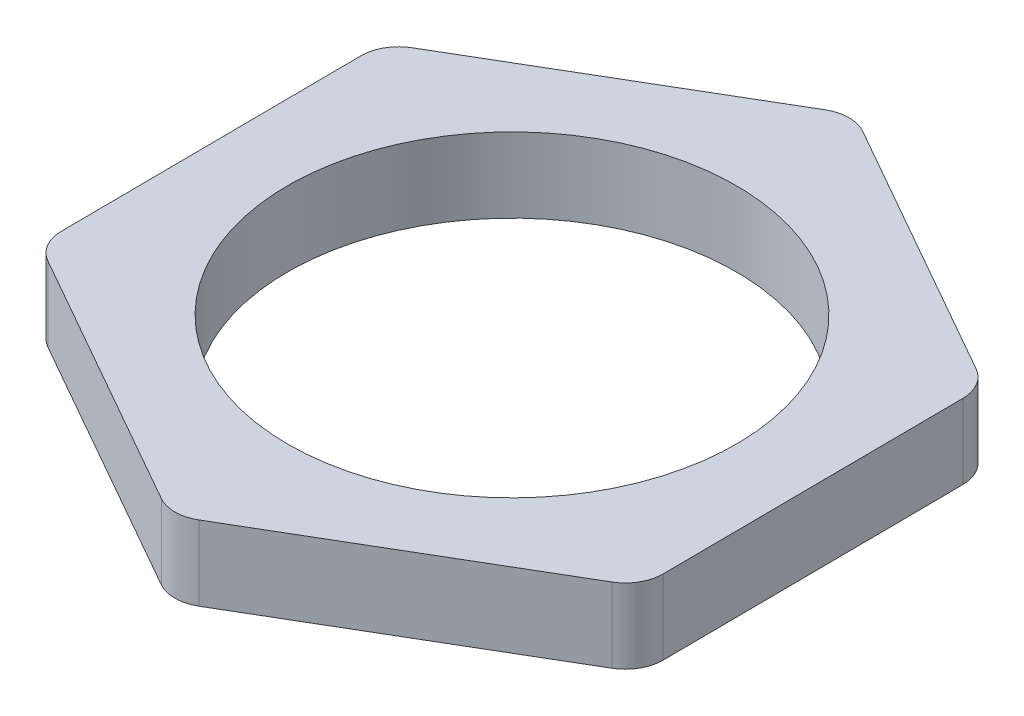
from build123d import *

# Parameters (mm, degrees)
SKETCH1_R           = 6
BOSS_EXTRUDE1_DEPTH = 2
FILLET1_R           = 1


with BuildPart() as part:
    # Sketch1 → Boss-Extrude1 (new body)
    with BuildSketch(Plane(origin=(0, 0, 0), x_dir=(1, 0, 0), z_dir=(0, 1, 0))):
        Polygon((7.966349656, 4.676602025), (-0.066881329, 9.23736219), (-8.033230985, 4.560760165), (-7.966349656, -4.676602025), (0.066881329, -9.23736219), (8.033230985, -4.560760165), align=None)
        Circle(SKETCH1_R, mode=Mode.SUBTRACT)
    extrude(amount=BOSS_EXTRUDE1_DEPTH)

    # Fillet1
    fillet1_edges = [part.edges().sort_by_distance(p)[0] for p in [
        (8.033230985, 1, 4.560760165),
        (0.066881329, 1, 9.23736219),
        (-7.966349656, 1, 4.676602025),
        (-8.033230985, 1, -4.560760165),
        (-0.066881329, 1, -9.23736219),
        (7.966349656, 1, -4.676602025),
    ]]
    fillet(fillet1_edges, radius=FILLET1_R)


solid = part.part
